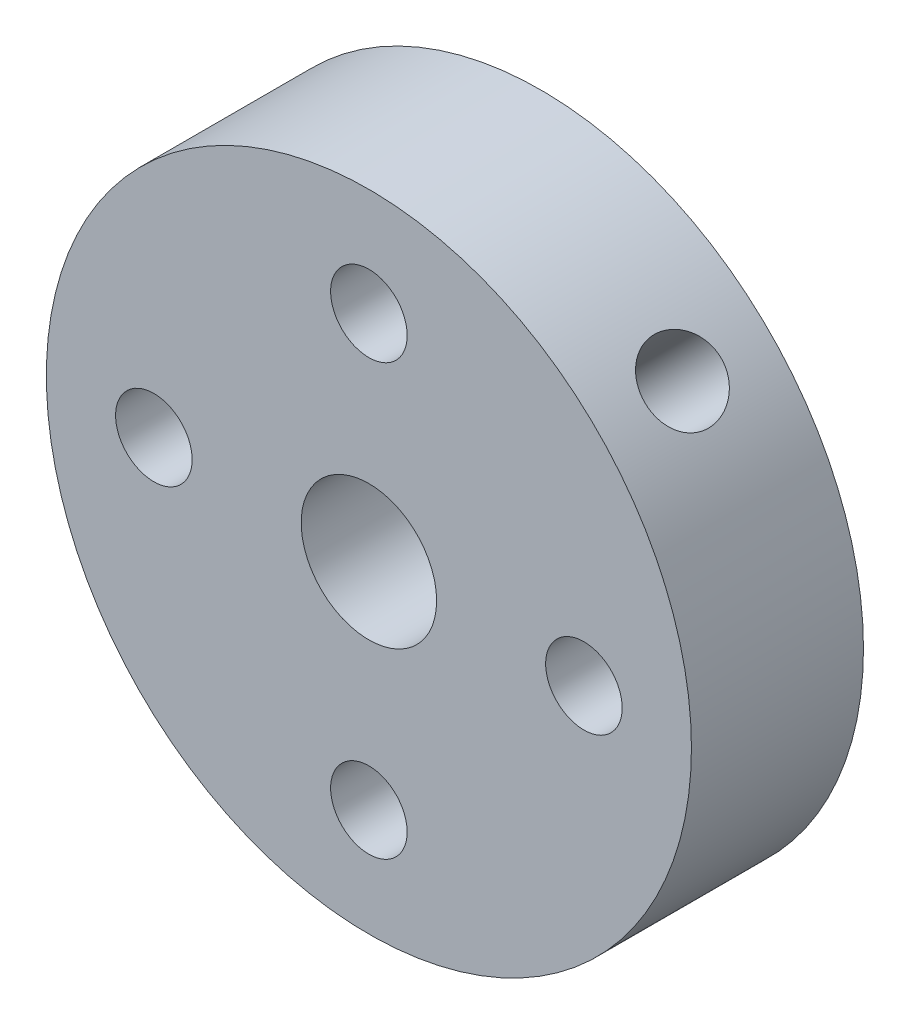
from build123d import *

# Parameters (mm, degrees)
SKETCH1_R           = 9.525
SKETCH1_R_2         = 2
SKETCH1_R_3         = 1.1303
BOSS_EXTRUDE1_DEPTH = 5.08
SKETCH2_R           = 1.1303
CUT_EXTRUDE1_DEPTH  = 10.16


with BuildPart() as part:
    # Sketch1 → Boss-Extrude1 (new body)
    with BuildSketch(Plane.XY):
        Circle(SKETCH1_R)
        Circle(SKETCH1_R_2, mode=Mode.SUBTRACT)
        with Locations((-6.35, 0)):
            Circle(SKETCH1_R_3, mode=Mode.SUBTRACT)
        with Locations((0, 6.35)):
            Circle(SKETCH1_R_3, mode=Mode.SUBTRACT)
        with Locations((6.35, 0)):
            Circle(SKETCH1_R_3, mode=Mode.SUBTRACT)
        with Locations((0, -6.35)):
            Circle(SKETCH1_R_3, mode=Mode.SUBTRACT)
    extrude(amount=BOSS_EXTRUDE1_DEPTH)

    # Sketch2 → Cut-Extrude1 (cut)
    with BuildSketch(Plane(origin=(6.735192091, 6.735192091, 0), x_dir=(-0.707106781, 0.707106781, 0), z_dir=(0.707106781, 0.707106781, 0))):
        with Locations((0, 2.54)):
            Circle(SKETCH2_R)
    extrude(amount=-CUT_EXTRUDE1_DEPTH, mode=Mode.SUBTRACT)


solid = part.part
